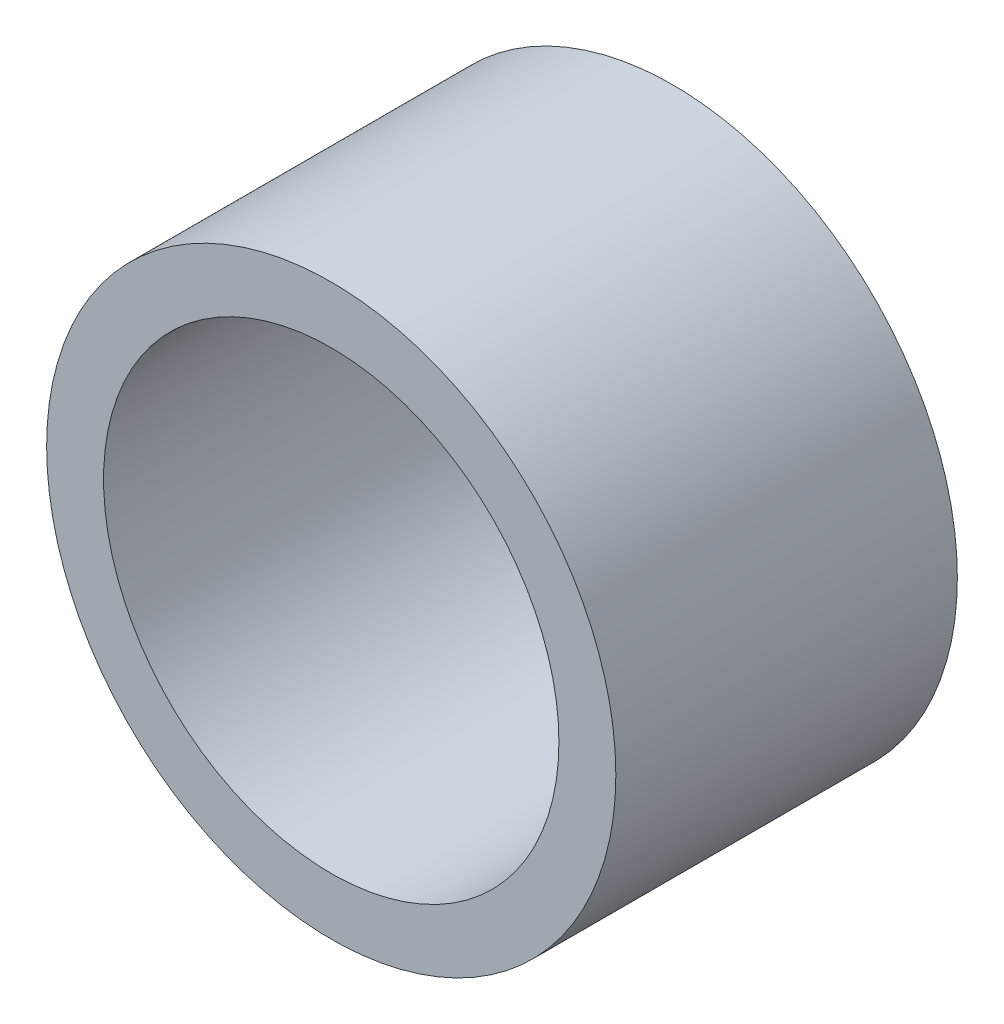
from build123d import *

# Parameters (mm, degrees)
SKETCH1_R           = 7.9375
SKETCH1_R_2         = 6.35
BOSS_EXTRUDE1_DEPTH = 9.525


with BuildPart() as part:
    # Sketch1 → Boss-Extrude1 (new body)
    with BuildSketch(Plane.XY):
        Circle(SKETCH1_R)
        Circle(SKETCH1_R_2, mode=Mode.SUBTRACT)
    extrude(amount=BOSS_EXTRUDE1_DEPTH)


solid = part.part
